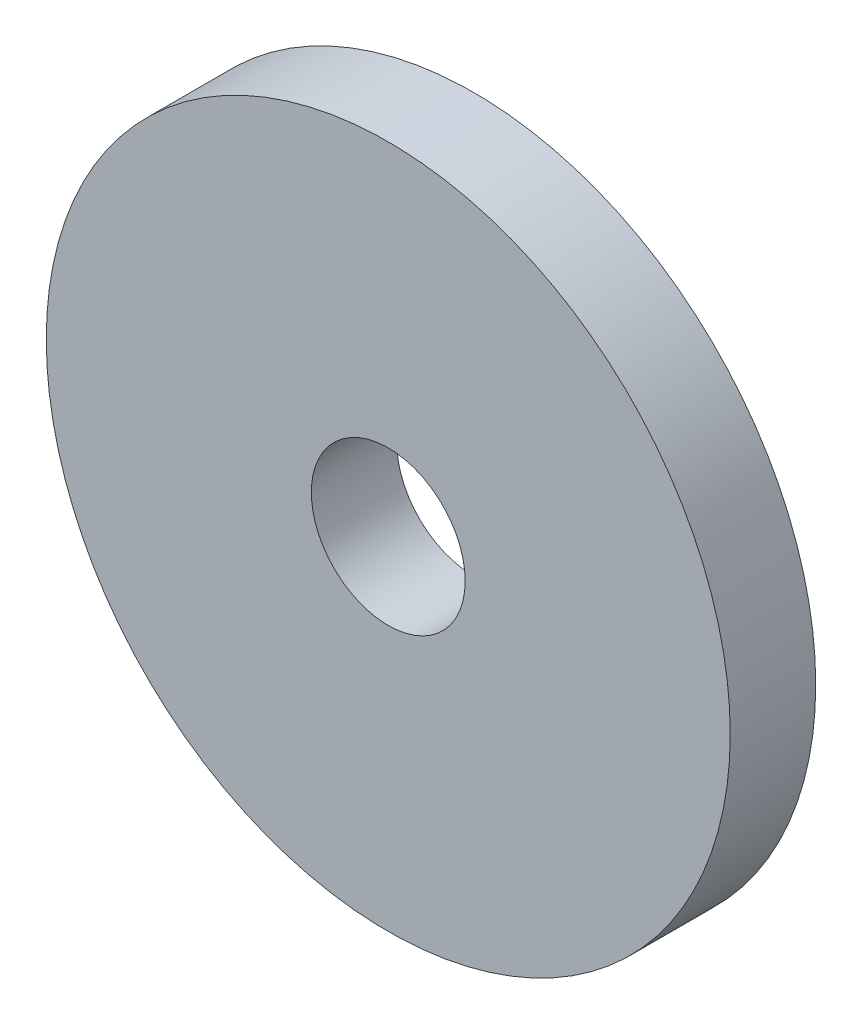
from build123d import *

# Parameters (mm, degrees)
SKETCH1_R           = 20
BOSS_EXTRUDE1_DEPTH = 5
SKETCH2_R           = 4.5
CUT_EXTRUDE1_DEPTH  = 5


with BuildPart() as part:
    # Sketch1 → Boss-Extrude1 (new body)
    with BuildSketch(Plane.XY):
        Circle(SKETCH1_R)
    extrude(amount=BOSS_EXTRUDE1_DEPTH)

    # Sketch2 → Cut-Extrude1 (cut)
    with BuildSketch(Plane.XY.offset(5)):
        Circle(SKETCH2_R)
    extrude(amount=-CUT_EXTRUDE1_DEPTH, mode=Mode.SUBTRACT)


solid = part.part
